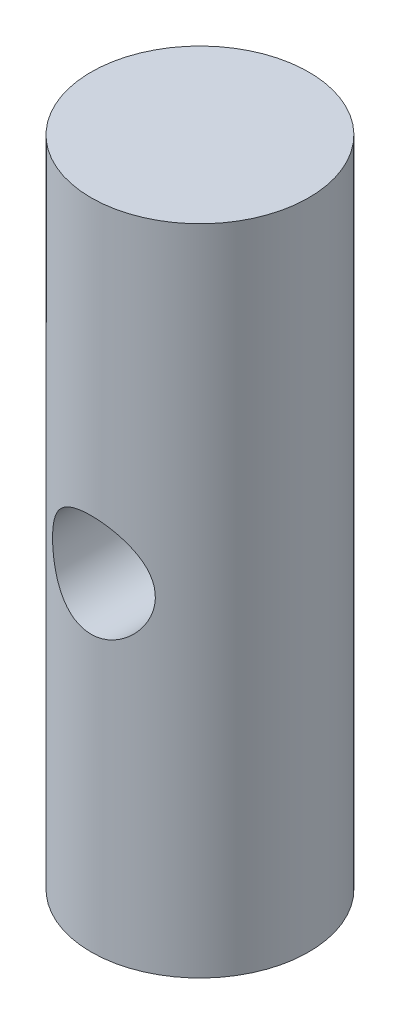
from build123d import *

# Parameters (mm, degrees)
SKETCH1_R                      = 3.175
BOSS_EXTRUDE1_DEPTH            = 19.05
CUT_EXTRUDE1_REACH             = 21.572
CUT_EXTRUDE1_END_RADIUS        = 3.175
SKETCH2_R                      = 1.4986
CUT_EXTRUDE1_DIRECTION_2_DEPTH = 19.05


with BuildPart() as part:
    # Sketch1 → Boss-Extrude1 (new body)
    with BuildSketch(Plane(origin=(0, 0, 0), x_dir=(1, 0, 0), z_dir=(0, 1, 0))):
        Circle(SKETCH1_R)
    extrude(amount=BOSS_EXTRUDE1_DEPTH)

    # Cut-Extrude1: up to this cylinder (the profile starts inside it)
    cut_extrude1_end = Plane(origin=(0, 9.525, 0), z_dir=(0, -1, 0)) * Cylinder(CUT_EXTRUDE1_END_RADIUS, 50.494, mode=Mode.PRIVATE)
    # Sketch2 → Cut-Extrude1 (cut, up to the surface)
    with BuildSketch(Plane.XY, mode=Mode.PRIVATE) as cut_extrude1_sk1:
        with Locations((0, 9.525)):
            Circle(SKETCH2_R)
    cut_extrude1_tool1 = extrude(cut_extrude1_sk1.sketch, amount=-CUT_EXTRUDE1_REACH, mode=Mode.PRIVATE) & cut_extrude1_end
    add(cut_extrude1_tool1.solids().sort_by_distance((0, 9.525, 0))[0], mode=Mode.SUBTRACT)

    # Sketch2 → Cut-Extrude1 direction 2 (cut)
    with BuildSketch(Plane.XY):
        with Locations((0, 9.525)):
            Circle(SKETCH2_R)
    extrude(amount=CUT_EXTRUDE1_DIRECTION_2_DEPTH, mode=Mode.SUBTRACT)


solid = part.part
